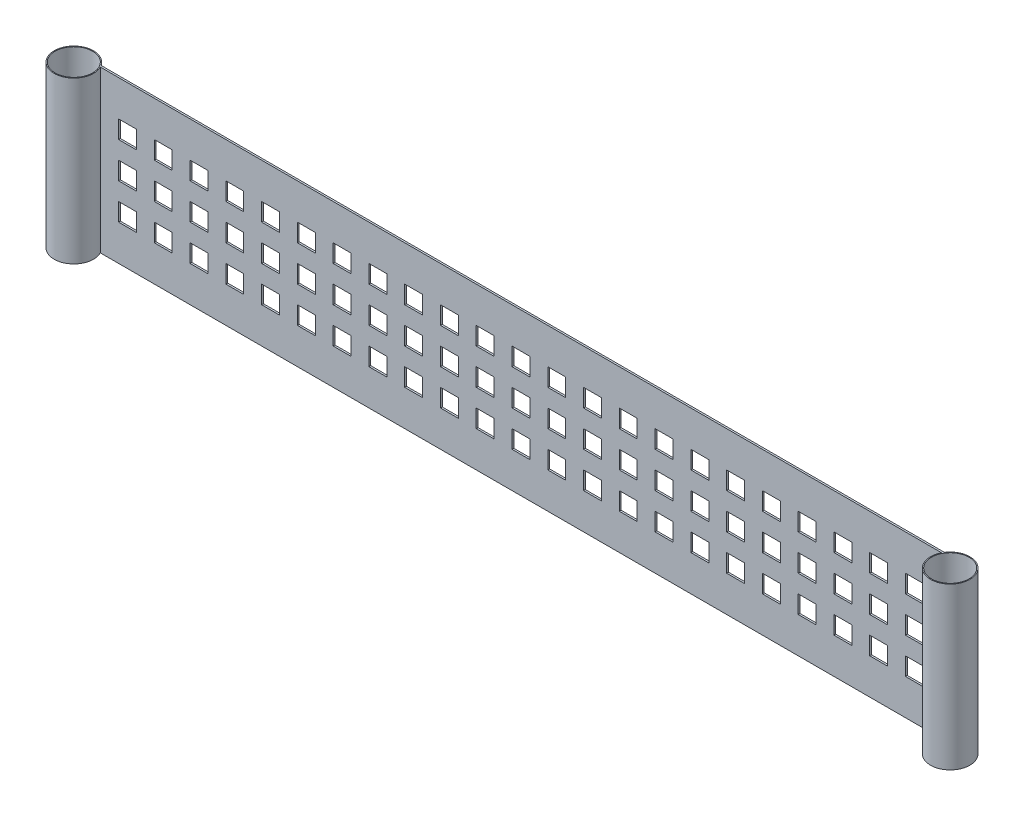
from build123d import *

# Parameters (mm, degrees)
SKETCH1_R               = 10.5
BOSS_EXTRUDE1_DEPTH     = 90
CUT_EXTRUDE1_DEPTH      = 510.271047675
CUT_EXTRUDE1_DEPTH_BACK = 510.271047675
SKETCH2_W               = 10
SKETCH2_H               = 10


with BuildPart() as part:
    # Sketch1 → Boss-Extrude1 (new body)
    with BuildSketch(Plane(origin=(0, 0, 0), x_dir=(1, 0, 0), z_dir=(0, 1, 0))):
        with BuildLine():
            Line((480.780455543, 6), (9.219544457, 6))
            ThreePointArc((9.219544457, 6), (-9.521888424, -5.507598464), (9.797958971, 5))
            Line((9.797958971, 5), (480.202041029, 5))
            ThreePointArc((480.202041029, 5), (499.521888424, -5.507598464), (480.780455543, 6))
        make_face()
        Circle(SKETCH1_R, mode=Mode.SUBTRACT)
        with Locations((490, 0)):
            Circle(SKETCH1_R, mode=Mode.SUBTRACT)
    extrude(amount=BOSS_EXTRUDE1_DEPTH)

    # Sketch2 → Cut-Extrude1 (cut, two sides: drawn at the far end of the back side and taken through both)
    with BuildSketch(Plane.XY.offset(-5).offset(-CUT_EXTRUDE1_DEPTH_BACK)):
        with Locations((25, 65)):
            Rectangle(SKETCH2_W, SKETCH2_H)
        with Locations((45, 65)):
            Rectangle(SKETCH2_W, SKETCH2_H)
        with Locations((65, 65)):
            Rectangle(SKETCH2_W, SKETCH2_H)
        with Locations((85, 65)):
            Rectangle(SKETCH2_W, SKETCH2_H)
        with Locations((105, 65)):
            Rectangle(SKETCH2_W, SKETCH2_H)
        with Locations((125, 65)):
            Rectangle(SKETCH2_W, SKETCH2_H)
        with Locations((145, 65)):
            Rectangle(SKETCH2_W, SKETCH2_H)
        with Locations((165, 65)):
            Rectangle(SKETCH2_W, SKETCH2_H)
        with Locations((185, 65)):
            Rectangle(SKETCH2_W, SKETCH2_H)
        with Locations((205, 65)):
            Rectangle(SKETCH2_W, SKETCH2_H)
        with Locations((225, 65)):
            Rectangle(SKETCH2_W, SKETCH2_H)
        with Locations((245, 65)):
            Rectangle(SKETCH2_W, SKETCH2_H)
        with Locations((265, 65)):
            Rectangle(SKETCH2_W, SKETCH2_H)
        with Locations((285, 65)):
            Rectangle(SKETCH2_W, SKETCH2_H)
        with Locations((305, 65)):
            Rectangle(SKETCH2_W, SKETCH2_H)
        with Locations((325, 65)):
            Rectangle(SKETCH2_W, SKETCH2_H)
        with Locations((345, 65)):
            Rectangle(SKETCH2_W, SKETCH2_H)
        with Locations((365, 65)):
            Rectangle(SKETCH2_W, SKETCH2_H)
        with Locations((385, 65)):
            Rectangle(SKETCH2_W, SKETCH2_H)
        with Locations((405, 65)):
            Rectangle(SKETCH2_W, SKETCH2_H)
        with Locations((425, 65)):
            Rectangle(SKETCH2_W, SKETCH2_H)
        with Locations((445, 65)):
            Rectangle(SKETCH2_W, SKETCH2_H)
        with Locations((465, 65)):
            Rectangle(SKETCH2_W, SKETCH2_H)
        with Locations((45, 45)):
            Rectangle(SKETCH2_W, SKETCH2_H)
        with Locations((65, 45)):
            Rectangle(SKETCH2_W, SKETCH2_H)
        with Locations((85, 45)):
            Rectangle(SKETCH2_W, SKETCH2_H)
        with Locations((105, 45)):
            Rectangle(SKETCH2_W, SKETCH2_H)
        with Locations((125, 45)):
            Rectangle(SKETCH2_W, SKETCH2_H)
        with Locations((145, 45)):
            Rectangle(SKETCH2_W, SKETCH2_H)
        with Locations((165, 45)):
            Rectangle(SKETCH2_W, SKETCH2_H)
        with Locations((185, 45)):
            Rectangle(SKETCH2_W, SKETCH2_H)
        with Locations((205, 45)):
            Rectangle(SKETCH2_W, SKETCH2_H)
        with Locations((225, 45)):
            Rectangle(SKETCH2_W, SKETCH2_H)
        with Locations((245, 45)):
            Rectangle(SKETCH2_W, SKETCH2_H)
        with Locations((265, 45)):
            Rectangle(SKETCH2_W, SKETCH2_H)
        with Locations((285, 45)):
            Rectangle(SKETCH2_W, SKETCH2_H)
        with Locations((305, 45)):
            Rectangle(SKETCH2_W, SKETCH2_H)
        with Locations((325, 45)):
            Rectangle(SKETCH2_W, SKETCH2_H)
        with Locations((345, 45)):
            Rectangle(SKETCH2_W, SKETCH2_H)
        with Locations((365, 45)):
            Rectangle(SKETCH2_W, SKETCH2_H)
        with Locations((385, 45)):
            Rectangle(SKETCH2_W, SKETCH2_H)
        with Locations((405, 45)):
            Rectangle(SKETCH2_W, SKETCH2_H)
        with Locations((425, 45)):
            Rectangle(SKETCH2_W, SKETCH2_H)
        with Locations((445, 45)):
            Rectangle(SKETCH2_W, SKETCH2_H)
        with Locations((465, 45)):
            Rectangle(SKETCH2_W, SKETCH2_H)
        with Locations((45, 25)):
            Rectangle(SKETCH2_W, SKETCH2_H)
        with Locations((65, 25)):
            Rectangle(SKETCH2_W, SKETCH2_H)
        with Locations((85, 25)):
            Rectangle(SKETCH2_W, SKETCH2_H)
        with Locations((105, 25)):
            Rectangle(SKETCH2_W, SKETCH2_H)
        with Locations((125, 25)):
            Rectangle(SKETCH2_W, SKETCH2_H)
        with Locations((145, 25)):
            Rectangle(SKETCH2_W, SKETCH2_H)
        with Locations((165, 25)):
            Rectangle(SKETCH2_W, SKETCH2_H)
        with Locations((185, 25)):
            Rectangle(SKETCH2_W, SKETCH2_H)
        with Locations((205, 25)):
            Rectangle(SKETCH2_W, SKETCH2_H)
        with Locations((225, 25)):
            Rectangle(SKETCH2_W, SKETCH2_H)
        with Locations((245, 25)):
            Rectangle(SKETCH2_W, SKETCH2_H)
        with Locations((265, 25)):
            Rectangle(SKETCH2_W, SKETCH2_H)
        with Locations((285, 25)):
            Rectangle(SKETCH2_W, SKETCH2_H)
        with Locations((305, 25)):
            Rectangle(SKETCH2_W, SKETCH2_H)
        with Locations((325, 25)):
            Rectangle(SKETCH2_W, SKETCH2_H)
        with Locations((345, 25)):
            Rectangle(SKETCH2_W, SKETCH2_H)
        with Locations((365, 25)):
            Rectangle(SKETCH2_W, SKETCH2_H)
        with Locations((385, 25)):
            Rectangle(SKETCH2_W, SKETCH2_H)
        with Locations((405, 25)):
            Rectangle(SKETCH2_W, SKETCH2_H)
        with Locations((425, 25)):
            Rectangle(SKETCH2_W, SKETCH2_H)
        with Locations((445, 25)):
            Rectangle(SKETCH2_W, SKETCH2_H)
        with Locations((465, 25)):
            Rectangle(SKETCH2_W, SKETCH2_H)
        with Locations((25, 45)):
            Rectangle(SKETCH2_W, SKETCH2_H)
        with Locations((25, 25)):
            Rectangle(SKETCH2_W, SKETCH2_H)
    extrude(amount=CUT_EXTRUDE1_DEPTH + CUT_EXTRUDE1_DEPTH_BACK, mode=Mode.SUBTRACT)


solid = part.part
